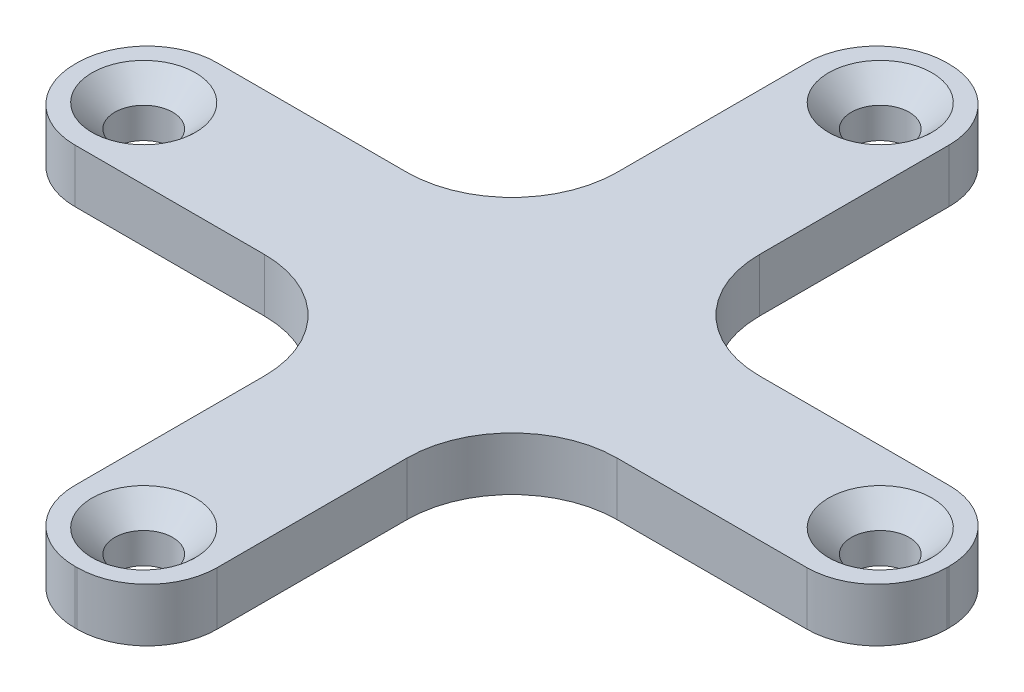
from build123d import *

# Parameters (mm, degrees)
SKETCH1_R           = 1.651
BOSS_EXTRUDE1_DEPTH = 3.048
FILLET3_R           = 4
CHAMFER1_SIZE       = 1.3
FILLET4_R           = 6


with BuildPart() as part:
    # Sketch1 → Boss-Extrude1 (new body)
    with BuildSketch(Plane(origin=(0, 0, 0), x_dir=(1, 0, 0), z_dir=(0, 1, 0))):
        Polygon((-24.895, 4.064), (-4.064, 4.064), (-4.064, 24.895), (4.064, 24.895), (4.064, 4.064), (24.895, 4.064), (24.895, -4.064), (4.064, -4.064), (4.064, -24.895), (-4.064, -24.895), (-4.064, -4.064), (-24.895, -4.064), align=None)
        with Locations((21.025, 0)):
            Circle(SKETCH1_R, mode=Mode.SUBTRACT)
        with Locations((0, 21.025)):
            Circle(SKETCH1_R, mode=Mode.SUBTRACT)
        with Locations((-21.025, 0)):
            Circle(SKETCH1_R, mode=Mode.SUBTRACT)
        with Locations((0, -21.025)):
            Circle(SKETCH1_R, mode=Mode.SUBTRACT)
    extrude(amount=BOSS_EXTRUDE1_DEPTH)

    # Fillet3
    fillet3_edges = [part.edges().sort_by_distance(p)[0] for p in [
        (4.064, 1.524, 24.895),
        (-4.064, 1.524, 24.895),
        (-24.895, 1.524, 4.064),
        (-24.895, 1.524, -4.064),
        (-4.064, 1.524, -24.895),
        (4.064, 1.524, -24.895),
        (24.895, 1.524, -4.064),
        (24.895, 1.524, 4.064),
    ]]
    fillet(fillet3_edges, radius=FILLET3_R)

    # Chamfer1
    chamfer1_edges = [part.edges().sort_by_distance(p)[0] for p in [
        (19.374, 3.048, 0),
        (-1.651, 3.048, -21.025),
        (-22.676, 3.048, 0),
        (-1.651, 3.048, 21.025),
    ]]
    chamfer(chamfer1_edges, length=CHAMFER1_SIZE)

    # Fillet4
    fillet4_edges = [part.edges().sort_by_distance(p)[0] for p in [
        (4.064, 1.524, 4.064),
        (-4.064, 1.524, 4.064),
        (-4.064, 1.524, -4.064),
        (4.064, 1.524, -4.064),
    ]]
    fillet(fillet4_edges, radius=FILLET4_R)


solid = part.part
